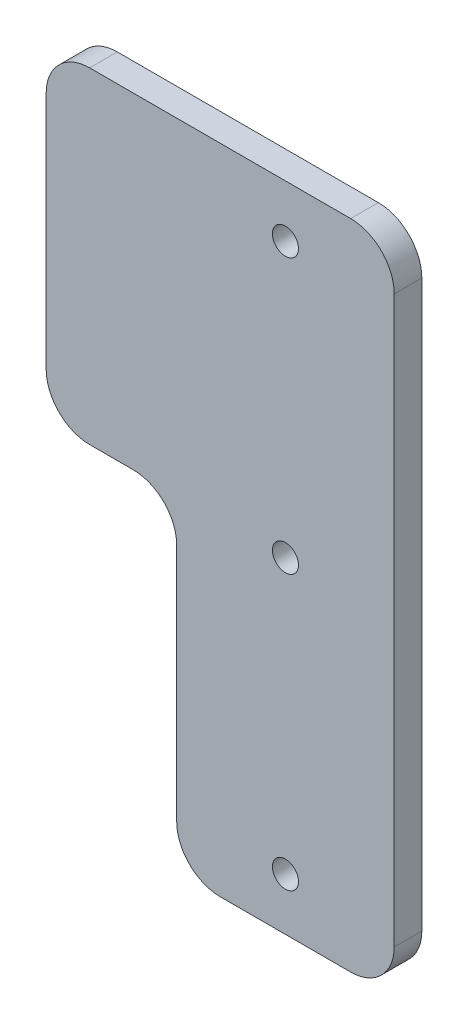
from build123d import *

# Parameters (mm, degrees)
SKETCH1_R           = 1.5
BOSS_EXTRUDE1_DEPTH = 3.175
FILLET1_R           = 5


with BuildPart() as part:
    # Sketch1 → Boss-Extrude1 (new body)
    with BuildSketch(Plane.XY):
        Polygon((0, 37.5), (0, 0), (25, 0), (25, 75), (-15, 75), (-15, 37.5), align=None)
        with Locations((12.5, 6)):
            Circle(SKETCH1_R, mode=Mode.SUBTRACT)
        with Locations((12.5, 37.5)):
            Circle(SKETCH1_R, mode=Mode.SUBTRACT)
        with Locations((12.5, 69)):
            Circle(SKETCH1_R, mode=Mode.SUBTRACT)
    extrude(amount=BOSS_EXTRUDE1_DEPTH)

    # Fillet1
    fillet1_edges = [part.edges().sort_by_distance(p)[0] for p in [
        (25, 75, 1.5875),
        (25, 0, 1.5875),
        (0, 0, 1.5875),
        (0, 37.5, 1.5875),
        (-15, 37.5, 1.5875),
        (-15, 75, 1.5875),
    ]]
    fillet(fillet1_edges, radius=FILLET1_R)


solid = part.part
